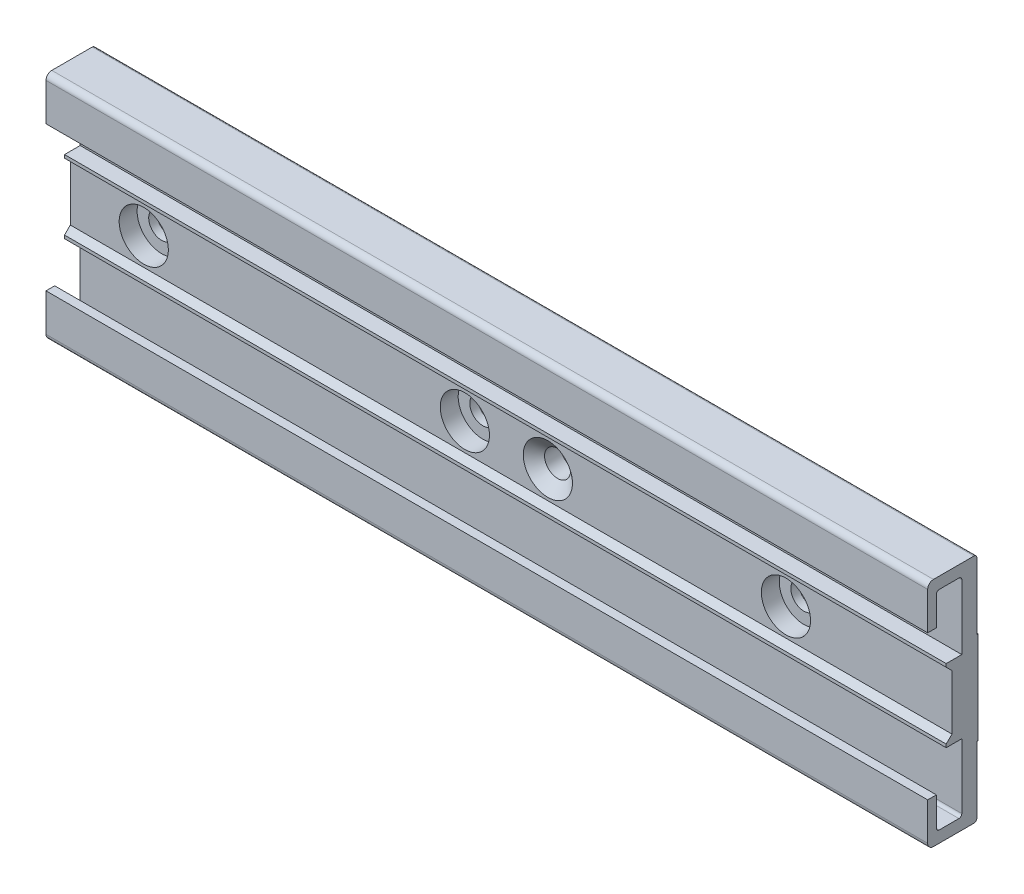
from build123d import *

# Parameters (mm, degrees)
BOSS_EXTRUDE1_DEPTH                                 = 152.4
CBORE_FOR_0_BINDING_HEAD_MACHINE_SCREW1_D           = 4.499991
CBORE_FOR_0_BINDING_HEAD_MACHINE_SCREW1_CBORE_D     = 8.5000084
CBORE_FOR_0_BINDING_HEAD_MACHINE_SCREW1_CBORE_DEPTH = 3.099999896
CSK_FOR_0_FLAT_HEAD_MACHINE_SCREW_100_D             = 4.499991
CSK_FOR_0_FLAT_HEAD_MACHINE_SCREW_100_CSINK_D       = 8.5000084
CSK_FOR_0_FLAT_HEAD_MACHINE_SCREW_100_CSINK_ANGLE   = 100


with BuildPart() as part:
    # Sketch1 → Boss-Extrude1 (new body)
    with BuildSketch(Plane(origin=(0, 0, 0), x_dir=(0, 0, -1), z_dir=(1, 0, 0))):
        with BuildLine():
            Line((-8.7, -12.5), (-8.7, -19))
            ThreePointArc((-8.7, -19), (-8.407106781, -19.707106781), (-7.7, -20))
            Line((-7.7, -20), (-0.7, -20))
            ThreePointArc((-0.7, -20), (-0.346446609, -19.853553391), (-0.2, -19.5))
            Line((-0.2, -19.5), (-0.2, -8))
            Line((-0.2, -8), (0, -8))
            Line((0, -8), (0, 8))
            Line((0, 8), (-0.2, 8))
            Line((-0.2, 8), (-0.2, 19.5))
            ThreePointArc((-0.2, 19.5), (-0.346446609, 19.853553391), (-0.7, 20))
            Line((-0.7, 20), (-7.7, 20))
            ThreePointArc((-7.7, 20), (-8.407106781, 19.707106781), (-8.7, 19))
            Line((-8.7, 19), (-8.7, 12.5))
            Line((-8.7, 12.5), (-7.2, 12.5))
            Line((-7.2, 12.5), (-7.2, 17.5))
            ThreePointArc((-7.2, 17.5), (-7.053553391, 17.853553391), (-6.7, 18))
            Line((-6.7, 18), (-3.3, 18))
            ThreePointArc((-3.3, 18), (-2.946446609, 17.853553391), (-2.8, 17.5))
            Line((-2.8, 17.5), (-2.8, 6.3))
            Line((-2.8, 6.3), (-5.5, 6.3))
            Line((-5.5, 6.3), (-5.5, 5.75))
            Line((-5.5, 5.75), (-4.5, 4.75))
            Line((-4.5, 4.75), (-4.5, -4.75))
            Line((-4.5, -4.75), (-5.5, -5.75))
            Line((-5.5, -5.75), (-5.5, -6.3))
            Line((-5.5, -6.3), (-2.8, -6.3))
            Line((-2.8, -6.3), (-2.8, -17.5))
            ThreePointArc((-2.8, -17.5), (-2.946446609, -17.853553391), (-3.3, -18))
            Line((-3.3, -18), (-6.7, -18))
            ThreePointArc((-6.7, -18), (-7.053553391, -17.853553391), (-7.2, -17.5))
            Line((-7.2, -17.5), (-7.2, -12.5))
            Line((-7.2, -12.5), (-8.7, -12.5))
        make_face()
    extrude(amount=BOSS_EXTRUDE1_DEPTH)

    # CBORE for #0 Binding Head Machine Screw1 (through all)
    with Locations(Plane.XY.offset(4.5)):
        with Locations((12.7, 0), (68.2, 0), (123.7, 0), (179.2, 0), (234.7, 0), (290.2, 0), (345.7, 0)):
            CounterBoreHole(CBORE_FOR_0_BINDING_HEAD_MACHINE_SCREW1_D / 2, CBORE_FOR_0_BINDING_HEAD_MACHINE_SCREW1_CBORE_D / 2, CBORE_FOR_0_BINDING_HEAD_MACHINE_SCREW1_CBORE_DEPTH)

    # CSK for #0 Flat Head Machine Screw (100)1 (through all)
    with Locations(Plane.XY.offset(4.5)):
        with Locations((82.55, 0)):
            CounterSinkHole(CSK_FOR_0_FLAT_HEAD_MACHINE_SCREW_100_D / 2, CSK_FOR_0_FLAT_HEAD_MACHINE_SCREW_100_CSINK_D / 2, counter_sink_angle=CSK_FOR_0_FLAT_HEAD_MACHINE_SCREW_100_CSINK_ANGLE)


solid = part.part
